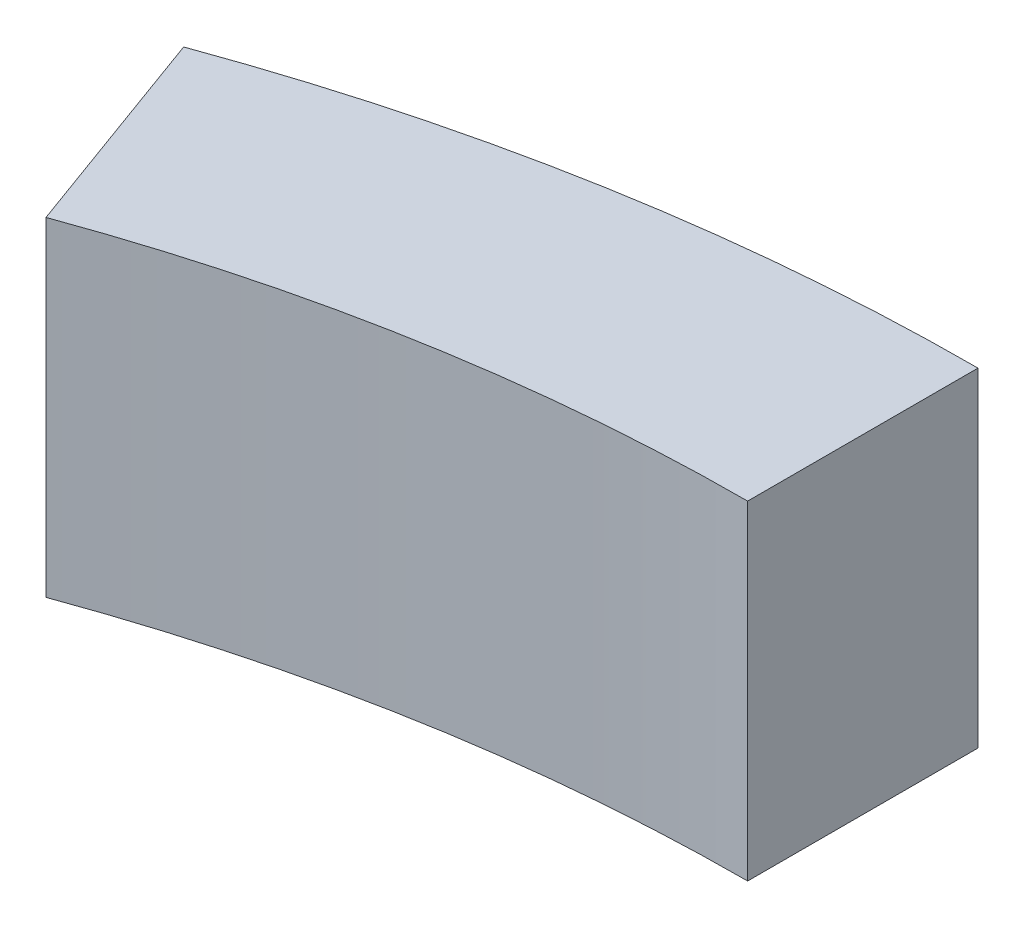
from build123d import *

# Parameters (mm, degrees)
AUFSATZ_LINEAR_AUSTRAGEN1_DEPTH = 10


with BuildPart() as part:
    # Skizze1 → Aufsatz-Linear austragen1 (new body)
    with BuildSketch(Plane(origin=(0, 0, 0), x_dir=(1, 0, 0), z_dir=(0, 1, 0))):
        with BuildLine():
            Line((-20.5212086, 56.381557247), (-18.127067596, 49.803708902))
            ThreePointArc((-18.127067596, 49.803708902), (-9.203353416, 52.19481091), (0, 53))
            Line((0, 53), (0, 60))
            ThreePointArc((0, 60), (-10.41889066, 59.088465181), (-20.5212086, 56.381557247))
        make_face()
    extrude(amount=AUFSATZ_LINEAR_AUSTRAGEN1_DEPTH)


solid = part.part
